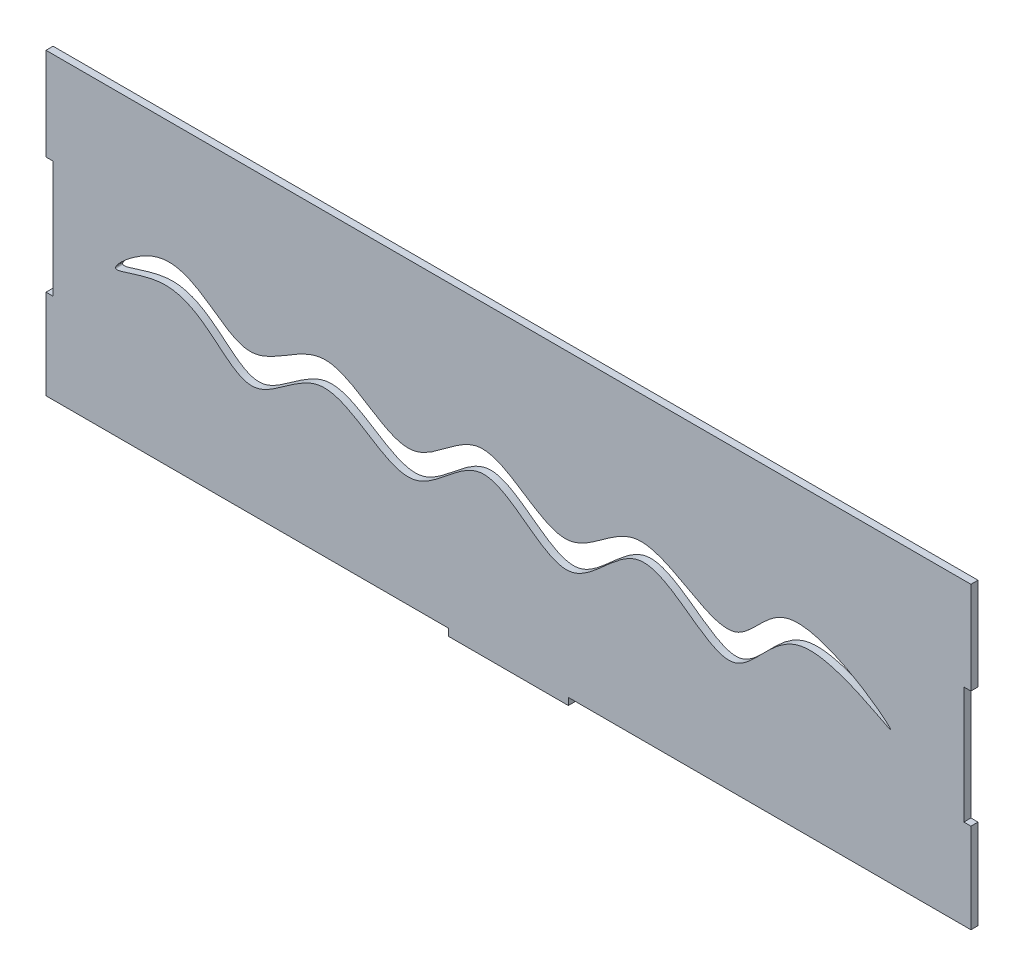
from build123d import *

# Parameters (mm, degrees)
SALIENTE_EXTRUIR1_DEPTH = 2.6
CORTAR_EXTRUIR1_DEPTH   = 10


with BuildPart() as part:
    # Croquis1 → Saliente-Extruir1 (new body)
    with BuildSketch(Plane.XY):
        Polygon((0, 0), (148, 0), (148, -2.6), (192, -2.6), (192, 0), (340, 0), (340, 33), (337.4, 33), (337.4, 76), (340, 76), (340, 110), (0, 110), (0, 76), (2.6, 76), (2.6, 33), (0, 33), align=None)
    extrude(amount=SALIENTE_EXTRUIR1_DEPTH)

    # Croquis2 → Cortar-Extruir1 (cut)
    with BuildSketch(Plane.XY.offset(2.6)):
        with BuildLine():
            add(Edge.make_bspline(
                [(25.644486083, 53.387697219), (24.841532179, 54.623955261), (50.111609888, 77.488967717), (71.921497243, 37.986782725), (103.997305336, 75.302724056), (133.0710576, 36.997774862), (160.789203194, 76.557941891), (190.514289438, 36.947235097), (218.600368953, 76.649523872), (252.186172312, 38.050552607), (272.65530802, 80.284957259), (332.239882377, 33.126191847), (272.870566121, 73.129275334), (253.074502661, 25.143398247), (218.953225352, 72.985546606), (191.921496129, 24.570437382), (161.294361754, 70.16339405), (133.511802205, 26.512484869), (103.389323527, 66.949212453), (72.322224849, 26.862879344), (54.613115636, 66.485340048), (26.402454627, 52.220700332), (25.644486083, 53.387697219)],
                knots=[0, 0, 0, 0, 0.029457288, 0.087860138, 0.134510113, 0.189310087, 0.234302886, 0.289414579, 0.334806909, 0.395127931, 0.432650559, 0.497950446, 0.552146891, 0.601857296, 0.659817271, 0.709437996, 0.765348966, 0.812065875, 0.869180282, 0.913062274, 0.972193051, 1, 1, 1, 1], degree=3))
        make_face()
    extrude(amount=-CORTAR_EXTRUIR1_DEPTH, mode=Mode.SUBTRACT)


solid = part.part
